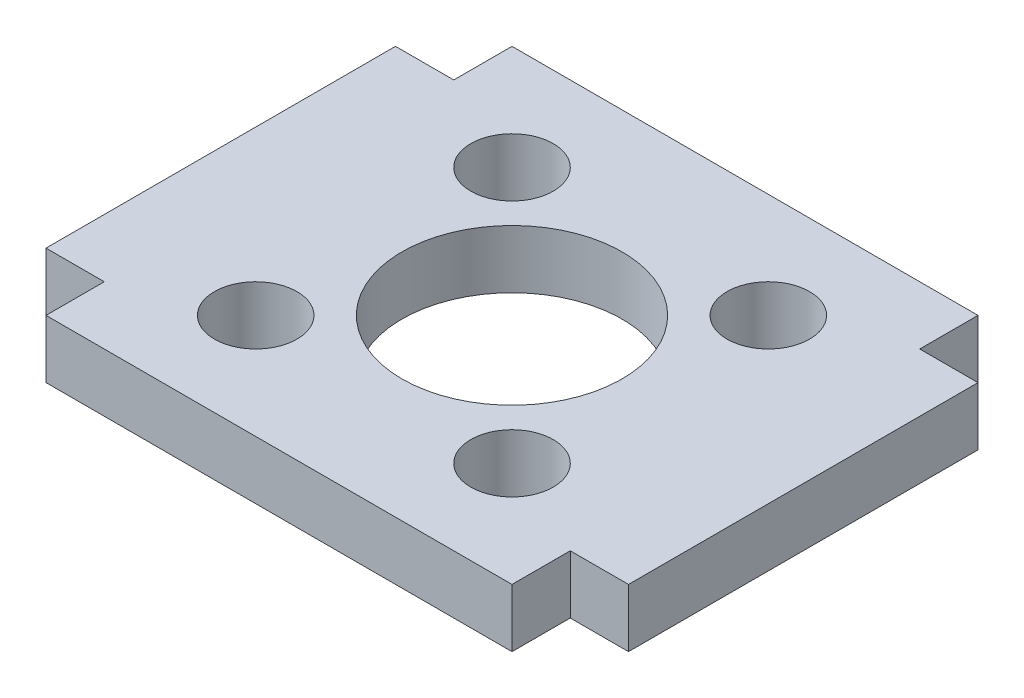
from build123d import *

# Parameters (mm, degrees)
BOSS_EXTRUDE1_DEPTH   = 3.175
SKETCH2_R             = 6
CUT_EXTRUDE1_DEPTH    = 4.175
F_8_CLEARANCE_HOLE1_D = 4.4958


with BuildPart() as part:
    # Sketch1 → Boss-Extrude1 (new body)
    with BuildSketch(Plane(origin=(0, 0, 0), x_dir=(1, 0, 0), z_dir=(0, 1, 0))):
        Polygon((-12.7, 9.525), (-15.875, 9.525), (-15.875, -9.525), (-12.7, -9.525), (-12.7, -12.7), (12.7, -12.7), (12.7, -9.525), (15.875, -9.525), (15.875, 9.525), (12.7, 9.525), (12.7, 12.7), (-12.7, 12.7), align=None)
    extrude(amount=BOSS_EXTRUDE1_DEPTH)

    # Sketch2 → Cut-Extrude1 (cut, through all)
    with BuildSketch(Plane(origin=(0, 3.175, 0), x_dir=(1, 0, 0), z_dir=(0, 1, 0))):
        Circle(SKETCH2_R)
    extrude(amount=-CUT_EXTRUDE1_DEPTH, mode=Mode.SUBTRACT)

    # #8 Clearance Hole1 (through all)
    with Locations(Plane(origin=(0, 3.175, 0), x_dir=(1, 0, 0), z_dir=(0, 1, 0))):
        with Locations((-6.985, 6.985), (6.985, 6.985), (6.985, -6.985), (-6.985, -6.985)):
            Hole(F_8_CLEARANCE_HOLE1_D / 2)


solid = part.part
